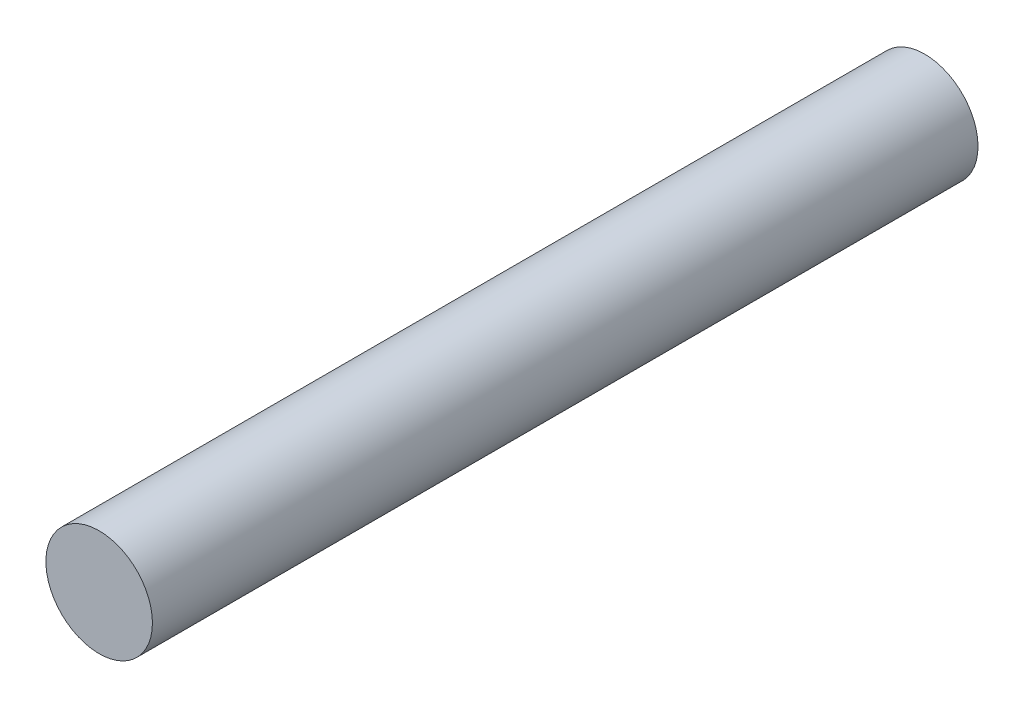
from build123d import *

# Parameters (mm, degrees)
SKETCH_1_R      = 4
EXTRUDE_1_DEPTH = 62


with BuildPart() as part:
    # 草图1 → 凸台-拉伸1 (new body)
    with BuildSketch(Plane.XY):
        Circle(SKETCH_1_R)
    extrude(amount=EXTRUDE_1_DEPTH)


solid = part.part
